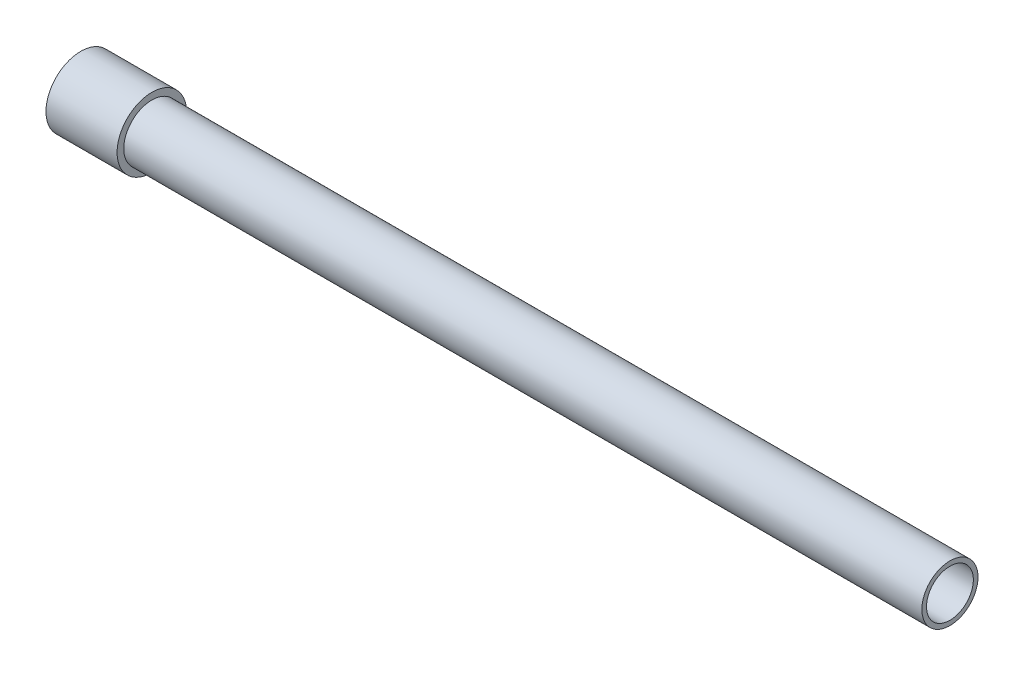
from build123d import *

# Parameters (mm, degrees)
SKETCH1_R           = 9.4
SKETCH1_R_2         = 7.85
BOSS_EXTRUDE1_DEPTH = 145.55
SKETCH2_R           = 11.65
SKETCH2_R_2         = 9.4
BOSS_EXTRUDE2_DEPTH = 23.8


with BuildPart() as part:
    # Sketch1 → Boss-Extrude1 (new, symmetric)
    with BuildSketch(Plane(origin=(0, 0, 0), x_dir=(0, 0, -1), z_dir=(1, 0, 0))):
        Circle(SKETCH1_R)
        Circle(SKETCH1_R_2, mode=Mode.SUBTRACT)
    extrude(amount=BOSS_EXTRUDE1_DEPTH, both=True)


with BuildPart() as body_2:
    # Sketch2 → Boss-Extrude2 (new body)
    with BuildSketch(Plane.ZY.offset(145.55)):
        Circle(SKETCH2_R)
        Circle(SKETCH2_R_2, mode=Mode.SUBTRACT)
    extrude(amount=-BOSS_EXTRUDE2_DEPTH)


solid = Compound([part.part, body_2.part])
